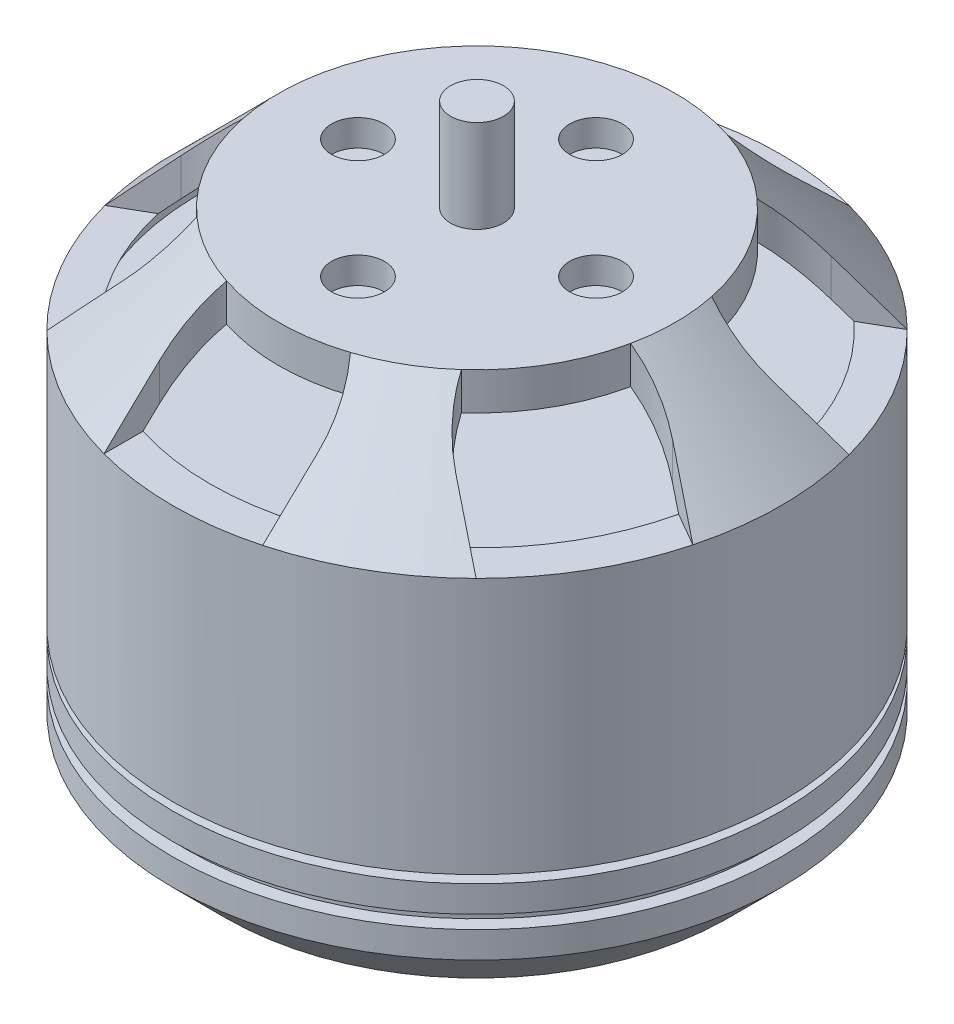
from build123d import *

# Parameters (mm, degrees)
SKETCH2_R          = 1
CUT_EXTRUDE1_DEPTH = 4
SKETCH3_R          = 1
CUT_EXTRUDE2_DEPTH = 3


with BuildPart() as part:
    # Sketch1 → Revolve1 (revolve)
    with BuildSketch(Plane.XY):
        Polygon((0, 20.293987171), (0, 0), (0, -3.506012829), (1, -3.506012829), (1, -1.706012829), (9.5, -1.706012829), (11.5, 0.293987171), (11.5, 1.293987171), (11, 1.293987171), (11, 1.793987171), (11.5, 1.793987171), (11.5, 2.793987171), (9.5, 2.793987171), (9.5, 3.093987171), (11.5, 3.093987171), (11.5, 12.793987171), (7.5, 16.793987171), (1, 16.793987171), (1, 20.293987171), align=None)
        Polygon((2, 15.793987171), (7.085786438, 15.793987171), (10.5, 12.379773609), (10.5, 11.992676837), (1, 11.992676837), (1, 14.793987171), (2, 14.793987171), align=None, mode=Mode.SUBTRACT)
    revolve(axis=Axis((0, 20.293987171, 0), (0, -1, 0)))

    # Sketch2 → Cut-Extrude1 (cut)
    with BuildSketch(Plane(origin=(0, 16.793987171, 0), x_dir=(1, 0, 0), z_dir=(0, 1, 0))):
        with BuildLine():
            ThreePointArc((-4.999493877, -5.590622592), (-6.495190528, -3.75), (-7.341368127, -1.534377408))
            ThreePointArc((-7.341368127, -1.534377408), (-8.349114086, -1.551762877), (-9.294228634, -1.901923789))
            Line((-9.294228634, -1.901923789), (-15.450860687, -5.456456962))
            Line((-15.450860687, -5.456456962), (-12.450860687, -10.652609385))
            Line((-12.450860687, -10.652609385), (-6.294228634, -7.098076211))
            ThreePointArc((-6.294228634, -7.098076211), (-5.518423115, -6.454663459), (-4.999493877, -5.590622592))
        make_face()
        with BuildLine():
            ThreePointArc((-7.341368127, 1.534377408), (-6.495190528, 3.75), (-4.999493877, 5.590622592))
            ThreePointArc((-4.999493877, 5.590622592), (-5.518423115, 6.454663459), (-6.294228634, 7.098076211))
            Line((-6.294228634, 7.098076211), (-12.450860687, 10.652609385))
            Line((-12.450860687, 10.652609385), (-15.450860687, 5.456456962))
            Line((-15.450860687, 5.456456962), (-9.294228634, 1.901923789))
            ThreePointArc((-9.294228634, 1.901923789), (-8.349114086, 1.551762877), (-7.341368127, 1.534377408))
        make_face()
        with BuildLine():
            Line((-3, 16.109066347), (-3, 9))
            ThreePointArc((-3, 9), (-2.830690971, 8.006426336), (-2.341874249, 7.125))
            ThreePointArc((-2.341874249, 7.125), (0, 7.5), (2.341874249, 7.125))
            ThreePointArc((2.341874249, 7.125), (2.830690971, 8.006426336), (3, 9))
            Line((3, 9), (3, 16.109066347))
            Line((3, 16.109066347), (-3, 16.109066347))
        make_face()
        with BuildLine():
            ThreePointArc((6.294228634, 7.098076211), (5.518423115, 6.454663459), (4.999493877, 5.590622592))
            ThreePointArc((4.999493877, 5.590622592), (6.495190528, 3.75), (7.341368127, 1.534377408))
            ThreePointArc((7.341368127, 1.534377408), (8.349114086, 1.551762877), (9.294228634, 1.901923789))
            Line((9.294228634, 1.901923789), (15.450860687, 5.456456962))
            Line((15.450860687, 5.456456962), (12.450860687, 10.652609385))
            Line((12.450860687, 10.652609385), (6.294228634, 7.098076211))
        make_face()
        with BuildLine():
            ThreePointArc((9.294228634, -1.901923789), (8.349114086, -1.551762877), (7.341368127, -1.534377408))
            ThreePointArc((7.341368127, -1.534377408), (6.495190528, -3.75), (4.999493877, -5.590622592))
            ThreePointArc((4.999493877, -5.590622592), (5.518423115, -6.454663459), (6.294228634, -7.098076211))
            Line((6.294228634, -7.098076211), (12.450860687, -10.652609385))
            Line((12.450860687, -10.652609385), (15.450860687, -5.456456962))
            Line((15.450860687, -5.456456962), (9.294228634, -1.901923789))
        make_face()
        with BuildLine():
            ThreePointArc((2.341874249, -7.125), (0, -7.5), (-2.341874249, -7.125))
            ThreePointArc((-2.341874249, -7.125), (-2.830690971, -8.006426336), (-3, -9))
            Line((-3, -9), (-3, -16.109066347))
            Line((-3, -16.109066347), (3, -16.109066347))
            Line((3, -16.109066347), (3, -9))
            ThreePointArc((3, -9), (2.830690971, -8.006426336), (2.341874249, -7.125))
        make_face()
        with Locations((0, -4.5)):
            Circle(SKETCH2_R)
        with Locations((-4.5, 0)):
            Circle(SKETCH2_R)
        with Locations((0, 4.5)):
            Circle(SKETCH2_R)
        with Locations((4.5, 0)):
            Circle(SKETCH2_R)
    extrude(amount=-CUT_EXTRUDE1_DEPTH, mode=Mode.SUBTRACT)

    # Sketch3 → Cut-Extrude2 (cut)
    with BuildSketch(Plane.XZ.offset(1.706012829)):
        with Locations((0, -6)):
            Circle(SKETCH3_R)
        with Locations((0, 6)):
            Circle(SKETCH3_R)
        with Locations((8, 0)):
            Circle(SKETCH3_R)
        with Locations((-8, 0)):
            Circle(SKETCH3_R)
    extrude(amount=-CUT_EXTRUDE2_DEPTH, mode=Mode.SUBTRACT)


solid = part.part
